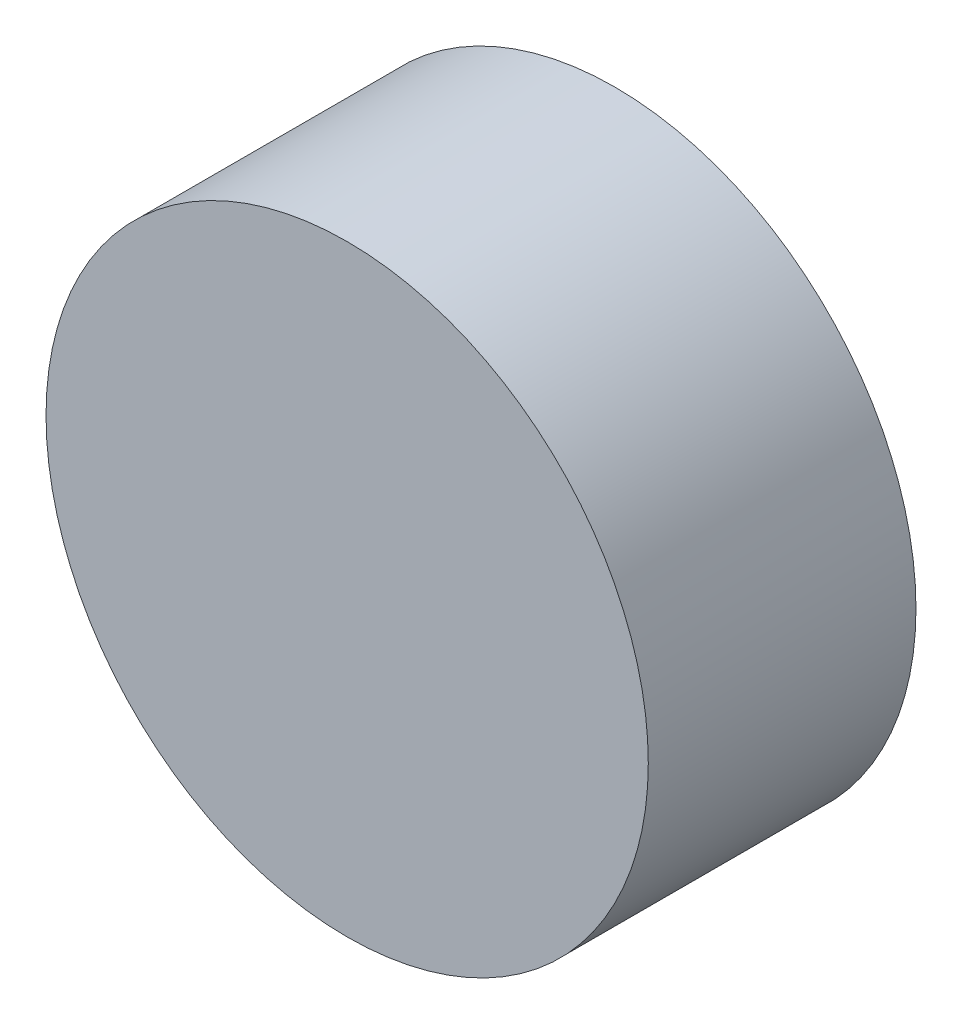
from build123d import *

# Parameters (mm, degrees)
SKETCH1_R           = 22.5
BOSS_EXTRUDE1_DEPTH = 20


with BuildPart() as part:
    # Sketch1 → Boss-Extrude1 (new body)
    with BuildSketch(Plane.XY):
        Circle(SKETCH1_R)
    extrude(amount=BOSS_EXTRUDE1_DEPTH)


solid = part.part
